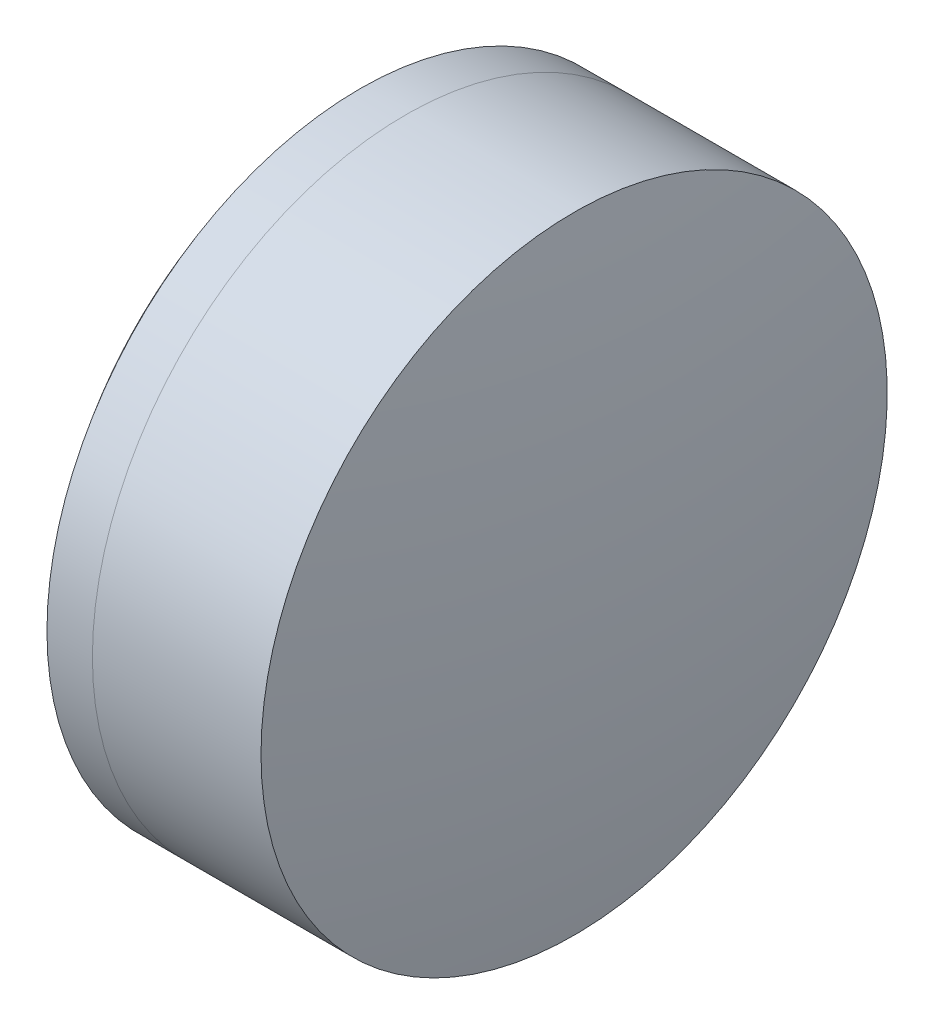
from build123d import *


with BuildPart() as part:
    # 草图1 one side → 旋转1 (revolve)
    with BuildSketch(Plane(origin=(0, 0, 0), x_dir=(1, 0, 0), z_dir=(0, 1, 0)), mode=Mode.PRIVATE) as revolve_1_sk:
        with BuildLine():
            ThreePointArc((219.540874627, 12.7), (216.344154889, 6.704296445), (215.239669764, 0))
            Line((215.239669764, 0), (227.239669764, 0))
            ThreePointArc((227.239669764, 0), (225.705267367, 6.992470906), (221.384023134, 12.7))
            Line((221.384023134, 12.7), (219.540874627, 12.7))
        make_face()
    revolve(revolve_1_sk.sketch.rotate(Axis((-9.702612178, 0, 0), (1, 0, 0)), 180), axis=Axis((-9.702612178, 0, 0), (1, 0, 0)))  # turned: the seam where the file's is


with BuildPart() as body_2:
    # 草图2 one side → 旋转3 (revolve)
    with BuildSketch(Plane(origin=(0, 0, 0), x_dir=(1, 0, 0), z_dir=(0, 1, 0)), mode=Mode.PRIVATE) as revolve_3_sk:
        with BuildLine():
            Line((228.222599387, 12.7), (221.384023134, 12.7))
            ThreePointArc((221.384023134, 12.7), (225.705267367, 6.992470906), (227.239669764, 0))
            Line((227.239669764, 0), (229.239669764, 0))
            ThreePointArc((229.239669764, 0), (228.984995786, 6.370330293), (228.222599387, 12.7))
        make_face()
    revolve(revolve_3_sk.sketch.rotate(Axis((-0.551919993, 0, 0), (1, 0, 0)), 180), axis=Axis((-0.551919993, 0, 0), (1, 0, 0)))  # turned: the seam where the file's is


solid = Compound([part.part, body_2.part])
